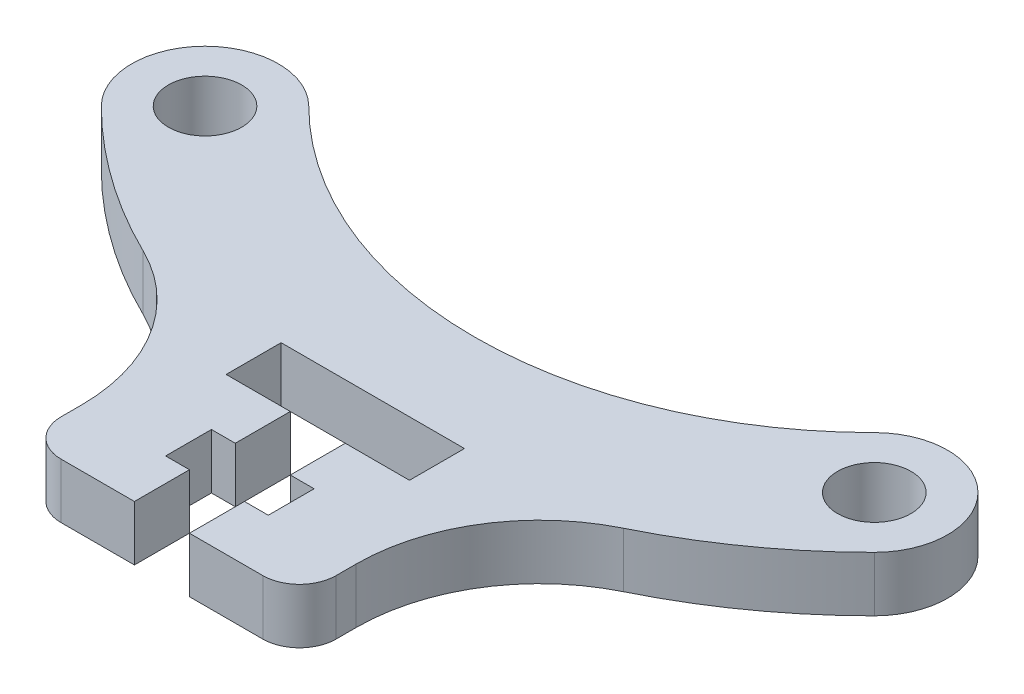
from build123d import *

# Parameters (mm, degrees)
SKETCH1_R           = 2
BOSS_EXTRUDE1_DEPTH = 3
BOSS_EXTRUDE2_DEPTH = 3
CUT_EXTRUDE2_DEPTH  = 3
FILLET1_R           = 10
FILLET2_R           = 2


with BuildPart() as part:
    # Sketch1 → Boss-Extrude1 (new body)
    with BuildSketch(Plane(origin=(0, 0, 0), x_dir=(1, 0, 0), z_dir=(0, 1, 0))):
        with BuildLine():
            ThreePointArc((15.4216389, 2.828493148), (21.078493148, 2.8283611), (21.0783611, -2.828493148))
            ThreePointArc((21.0783611, -2.828493148), (0, -11.559147965), (-21.0783611, -2.828493148))
            ThreePointArc((-21.0783611, -2.828493148), (-21.078493148, 2.8283611), (-15.4216389, 2.828493148))
            ThreePointArc((-15.4216389, 2.828493148), (0, -3.559147965), (15.4216389, 2.828493148))
        make_face()
        with Locations((18.25, 0)):
            Circle(SKETCH1_R, mode=Mode.SUBTRACT)
        with Locations((-18.25, 0)):
            Circle(SKETCH1_R, mode=Mode.SUBTRACT)
    extrude(amount=BOSS_EXTRUDE1_DEPTH)

    # Sketch2 → Boss-Extrude2 (add)
    with BuildSketch(Plane(origin=(0, 3, 0), x_dir=(1, 0, 0), z_dir=(0, 1, 0))):
        with BuildLine():
            Line((-7.5, -10.600250197), (-7.5, -20.600250197))
            Line((-7.5, -20.600250197), (7.5, -20.600250197))
            Line((7.5, -20.600250197), (7.5, -10.600250197))
            ThreePointArc((7.5, -10.600250197), (0, -11.559147965), (-7.5, -10.600250197))
        make_face()
    extrude(amount=-BOSS_EXTRUDE2_DEPTH)

    # Sketch4 → Cut-Extrude2 (cut)
    with BuildSketch(Plane(origin=(0, 3, 0), x_dir=(1, 0, 0), z_dir=(0, 1, 0))):
        Polygon((-1.5, -20.600250197), (-1.5, -17.600250197), (-2.8, -17.600250197), (-2.8, -15.100250197), (-1.5, -15.100250197), (-1.5, -12.100250197), (-5, -12.100250197), (-5, -9.100250197), (5, -9.100250197), (5, -12.100250197), (1.5, -12.100250197), (1.5, -15.100250197), (2.8, -15.100250197), (2.8, -17.600250197), (1.5, -17.600250197), (1.5, -20.600250197), align=None)
    extrude(amount=-CUT_EXTRUDE2_DEPTH, mode=Mode.SUBTRACT)

    # Fillet1
    fillet1_edges = [part.edges().sort_by_distance(p)[0] for p in [
        (-7.5, 1.5, 10.600250197),
        (7.5, 1.5, 10.600250197),
    ]]
    fillet(fillet1_edges, radius=FILLET1_R)

    # Fillet2
    fillet2_edges = [part.edges().sort_by_distance(p)[0] for p in [
        (7.5, 1.5, 20.600250197),
        (-7.5, 1.5, 20.600250197),
    ]]
    fillet(fillet2_edges, radius=FILLET2_R)


solid = part.part
